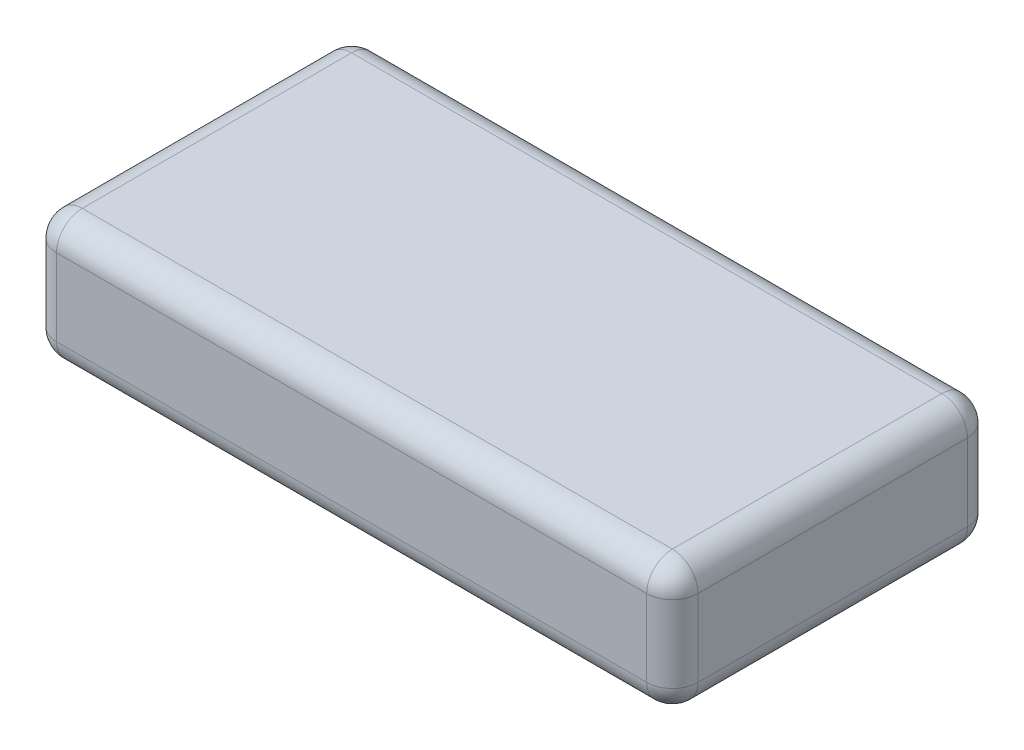
from build123d import *

# Parameters (mm, degrees)
SKETCH_1_W      = 10
SKETCH_1_H      = 5
EXTRUDE_1_DEPTH = 2
FILLET_1_R      = 0.4


with BuildPart() as part:
    # 草图1 → 凸台-拉伸1 (new body)
    with BuildSketch(Plane(origin=(0, 0, 0), x_dir=(1, 0, 0), z_dir=(0, 1, 0))):
        with Locations((5, -2.5)):
            Rectangle(SKETCH_1_W, SKETCH_1_H)
    extrude(amount=EXTRUDE_1_DEPTH)

    # 圆角1
    fillet_1_edges = [part.edges().sort_by_distance(p)[0] for p in [
        (10, 2, 2.5),
        (5, 2, 0),
        (0, 2, 2.5),
        (5, 0, 0),
        (10, 0, 2.5),
        (5, 0, 5),
        (0, 0, 2.5),
        (0, 1, 0),
        (10, 1, 0),
        (10, 1, 5),
        (0, 1, 5),
        (5, 2, 5),
    ]]
    fillet(fillet_1_edges, radius=FILLET_1_R)


solid = part.part
